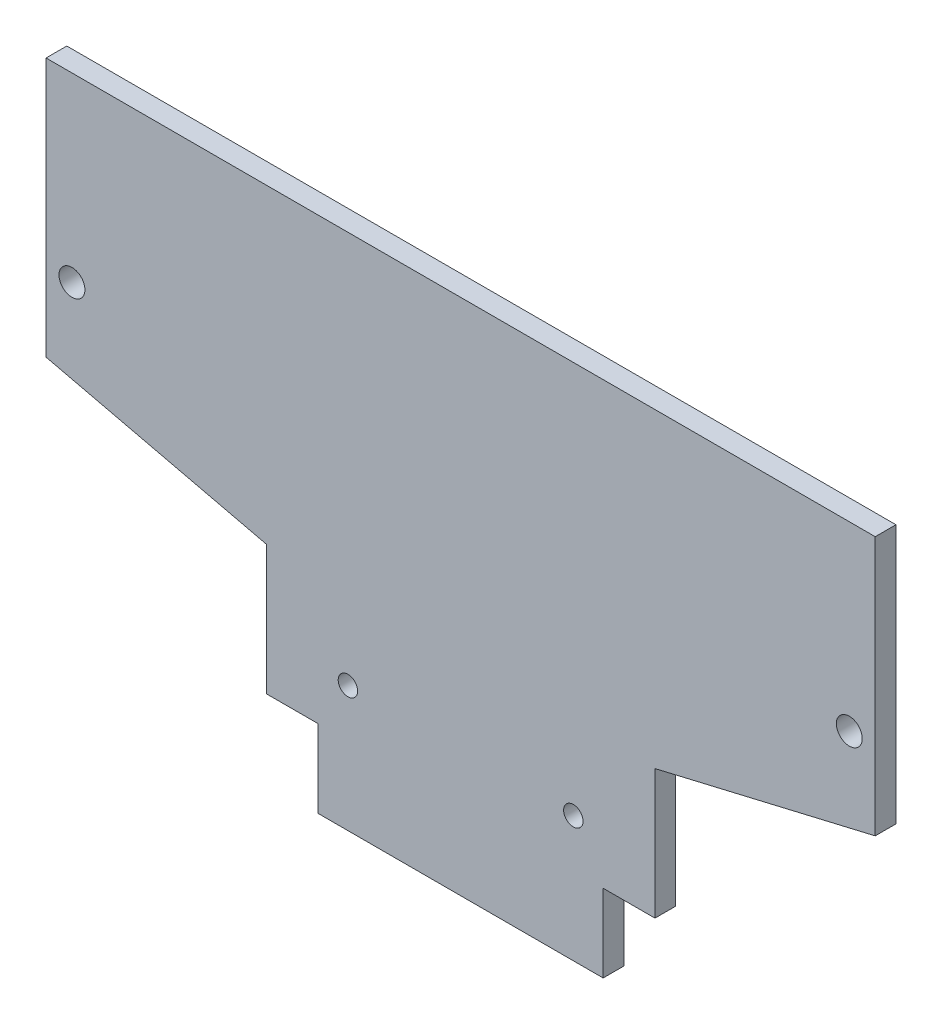
from build123d import *

# Parameters (mm, degrees)
SKETCH4_R           = 1
SKETCH4_R_2         = 0.75
BOSS_EXTRUDE1_DEPTH = 1.6


with BuildPart() as part:
    # Sketch4 → Boss-Extrude1 (new body)
    with BuildSketch(Plane.XY):
        Polygon((0, 40), (-32, 40), (-32, 20), (-15, 16), (-15, 6), (-11, 6), (-11, 0), (0, 0), align=None)
        with Locations((-30, 26)):
            Circle(SKETCH4_R, mode=Mode.SUBTRACT)
        with Locations((-8.7, 9.7)):
            Circle(SKETCH4_R_2, mode=Mode.SUBTRACT)
    boss_extrude1 = extrude(amount=BOSS_EXTRUDE1_DEPTH)

    # Mirror1: Boss-Extrude1 across plane
    add(boss_extrude1.mirror(Plane(origin=(0, 0, 1.6), x_dir=(0, 0, 1), z_dir=(-1, 0, 0))))


solid = part.part
